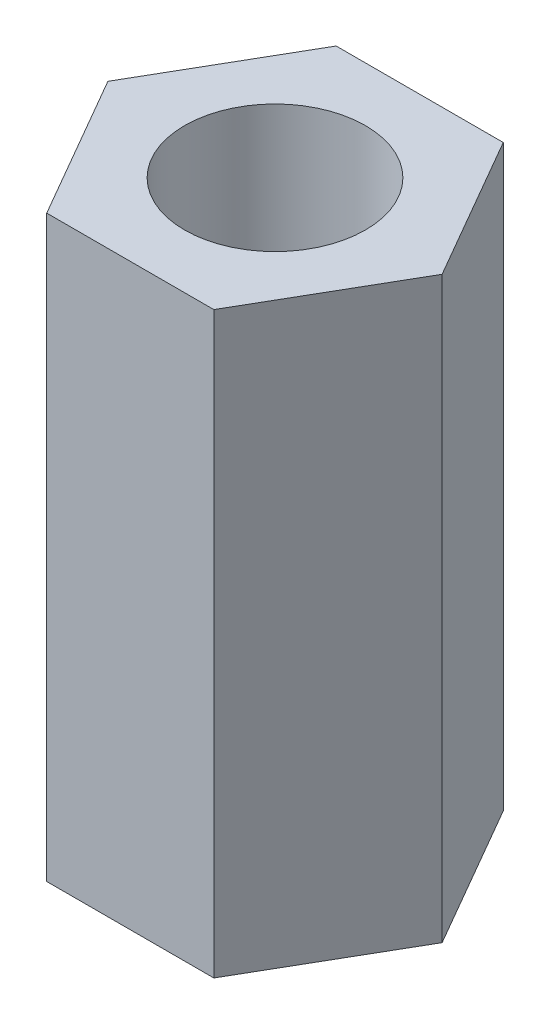
from build123d import *

# Parameters (mm, degrees)
SKETCH1_R           = 1.984375
BOSS_EXTRUDE1_DEPTH = 12.7


with BuildPart() as part:
    # Sketch1 → Boss-Extrude1 (new body)
    with BuildSketch(Plane(origin=(0, 0, 0), x_dir=(1, 0, 0), z_dir=(0, 1, 0))):
        Polygon((1.833087105, -3.175), (3.666174209, 0), (1.833087105, 3.175), (-1.833087105, 3.175), (-3.666174209, 0), (-1.833087105, -3.175), align=None)
        Circle(SKETCH1_R, mode=Mode.SUBTRACT)
    extrude(amount=BOSS_EXTRUDE1_DEPTH)


solid = part.part
